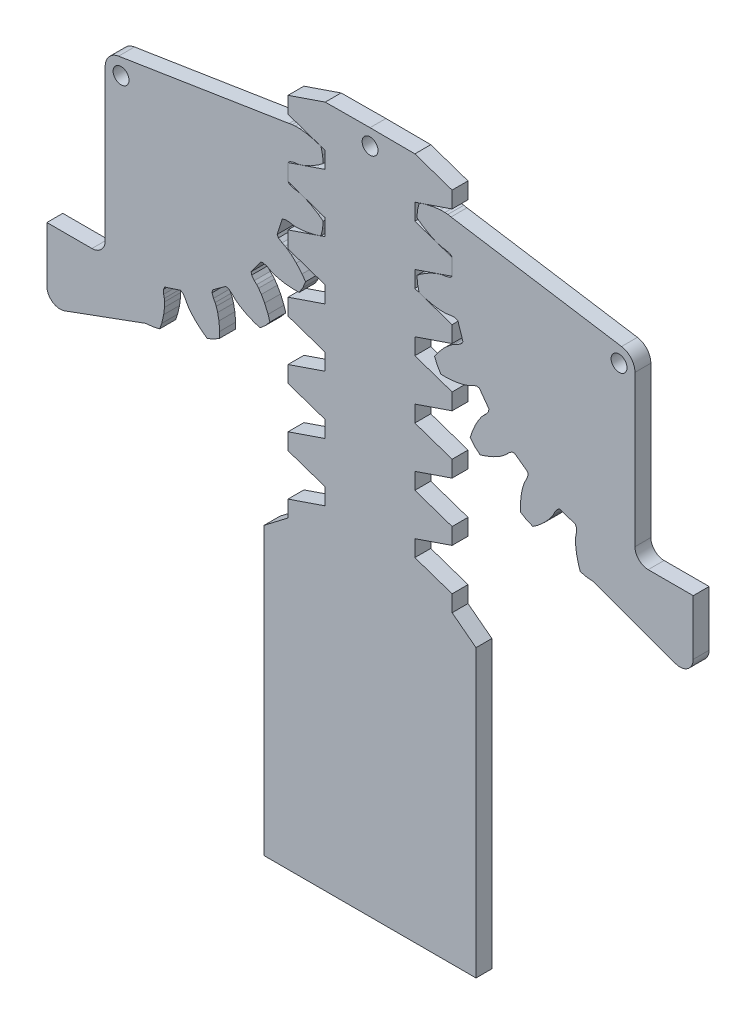
from build123d import *

# Parameters (mm, degrees)
MODEL_R            = 3
BOSS_EXTRU_1_DEPTH = 6
MODEL_4_R          = 3
BOSS_EXTRU_2_DEPTH = 6
MODEL_5_R          = 3
BOSS_EXTRU_3_DEPTH = 6


with BuildPart() as part:
    # Model → Boss.-Extru.1 (new body)
    with BuildSketch(Plane.XY):
        Polygon((-40, 168), (-40, 60), (0, 60), (40, 60), (40, 168), (30.974642536, 174.908406866), (30.974642536, 181.091593134), (16.919007544, 185.898903429), (16.919007544, 192.101096571), (30.974642536, 196.908406866), (30.974642536, 203.091593134), (16.919007544, 207.898903429), (16.919007544, 214.101096571), (30.974642536, 218.908406866), (30.974642536, 225.091593134), (16.919007544, 229.898903429), (16.919007544, 236.101096571), (30.974642536, 240.908406866), (30.974642536, 247.091593134), (16.919007544, 251.898903429), (16.919007544, 258.101096571), (30.974642536, 262.908406866), (30.974642536, 269.091593134), (16.919007544, 273.898903429), (16.919007544, 280.101096571), (30.974642536, 284.908406866), (30.974642536, 291.091593134), (16.919007544, 295.898903429), (16.919007544, 302.101096571), (30.974642536, 306.908406866), (30.974642536, 313.091593134), (16.919007544, 317.898903429), (0, 318), (-16.919007544, 317.898903429), (-30.974642536, 313.091593134), (-30.974642536, 306.908406866), (-16.919007544, 302.101096571), (-16.919007544, 295.898903429), (-30.974642536, 291.091593134), (-30.974642536, 284.908406866), (-16.919007544, 280.101096571), (-16.919007544, 273.898903429), (-30.974642536, 269.091593134), (-30.974642536, 262.908406866), (-16.919007544, 258.101096571), (-16.919007544, 251.898903429), (-30.974642536, 247.091593134), (-30.974642536, 240.908406866), (-16.919007544, 236.101096571), (-16.919007544, 229.898903429), (-30.974642536, 225.091593134), (-30.974642536, 218.908406866), (-16.919007544, 214.101096571), (-16.919007544, 207.898903429), (-30.974642536, 203.091593134), (-30.974642536, 196.908406866), (-16.919007544, 192.101096571), (-16.919007544, 185.898903429), (-30.974642536, 181.091593134), (-30.974642536, 174.908406866), align=None)
        with Locations((0, 312)):
            Circle(MODEL_R, mode=Mode.SUBTRACT)
    extrude(amount=BOSS_EXTRU_1_DEPTH)


with BuildPart() as body_2:
    # Model_4 → Boss.-Extru.2 (new body)
    with BuildSketch(Plane.XY):
        with BuildLine():
            Line((-24.68488417, 293.282723858), (-26.413806818, 292.691397487))
            Line((-26.413806818, 292.691397487), (-27.486087265, 292.446172482))
            Line((-27.486087265, 292.446172482), (-28.703913807, 292.299193468))
            Line((-28.703913807, 292.299193468), (-30.277542749, 291.807781018))
            Line((-30.277542749, 291.807781018), (-31.024642536, 291.114398793))
            Line((-31.024642536, 291.114398793), (-31.024642536, 284.885601207))
            Line((-31.024642536, 284.885601207), (-30.277542749, 284.192218982))
            Line((-30.277542749, 284.192218982), (-28.703913807, 283.700806532))
            Line((-28.703913807, 283.700806532), (-27.486087265, 283.553827518))
            Line((-27.486087265, 283.553827518), (-26.413806818, 283.308602513))
            Line((-26.413806818, 283.308602513), (-24.68488417, 282.717276142))
            Line((-24.68488417, 282.717276142), (-22.367465587, 281.642464729))
            Line((-22.367465587, 281.642464729), (-19.55091319, 279.95801306))
            Line((-19.55091319, 279.95801306), (-17.710599237, 278.577184116))
            Line((-17.710599237, 278.577184116), (-17.917386886, 275.949697904))
            Line((-17.917386886, 275.949697904), (-18.532658037, 273.386909122))
            Line((-18.532658037, 273.386909122), (-20.709600224, 272.642351043))
            Line((-20.709600224, 272.642351043), (-23.908824927, 271.910704863))
            Line((-23.908824927, 271.910704863), (-26.444955963, 271.604620191))
            Line((-26.444955963, 271.604620191), (-28.271989012, 271.576501872))
            Line((-28.271989012, 271.576501872), (-29.367567013, 271.674631914))
            Line((-29.367567013, 271.674631914), (-30.571207893, 271.911175663))
            Line((-30.571207893, 271.911175663), (-32.219672752, 271.930092736))
            Line((-32.219672752, 271.930092736), (-33.144473763, 271.501513584))
            Line((-33.144473763, 271.501513584), (-35.069278072, 265.57757505))
            Line((-35.069278072, 265.57757505), (-34.573010843, 264.687262837))
            Line((-34.573010843, 264.687262837), (-33.228255581, 263.733623737))
            Line((-33.228255581, 263.733623737), (-32.115452726, 263.217509291))
            Line((-32.115452726, 263.217509291), (-31.171432113, 262.652933571))
            Line((-31.171432113, 262.652933571), (-29.709858861, 261.556282292))
            Line((-29.709858861, 261.556282292), (-27.837997809, 259.817954169))
            Line((-27.837997809, 259.817954169), (-25.67982149, 257.345582877))
            Line((-25.67982149, 257.345582877), (-24.356278523, 255.463648225))
            Line((-24.356278523, 255.463648225), (-25.364883157, 253.028661239))
            Line((-25.364883157, 253.028661239), (-26.74198608, 250.781433511))
            Line((-26.74198608, 250.781433511), (-29.042462232, 250.746028829))
            Line((-29.042462232, 250.746028829), (-32.311196837, 251.038806764))
            Line((-32.311196837, 251.038806764), (-34.81778615, 251.531410532))
            Line((-34.81778615, 251.531410532), (-36.564086875, 252.069252683))
            Line((-36.564086875, 252.069252683), (-37.575719621, 252.50113212))
            Line((-37.575719621, 252.50113212), (-38.647354086, 253.098044081))
            Line((-38.647354086, 253.098044081), (-40.209291635, 253.625438942))
            Line((-40.209291635, 253.625438942), (-41.221267904, 253.503615176))
            Line((-41.221267904, 253.503615176), (-44.882463265, 248.464412073))
            Line((-44.882463265, 248.464412073), (-44.685606687, 247.464319834))
            Line((-44.685606687, 247.464319834), (-43.701359121, 246.141802925))
            Line((-43.701359121, 246.141802925), (-42.802508849, 245.307073925))
            Line((-42.802508849, 245.307073925), (-42.079155386, 244.478412095))
            Line((-42.079155386, 244.478412095), (-41.028000502, 242.983783776))
            Line((-41.028000502, 242.983783776), (-39.784927783, 240.752098611))
            Line((-39.784927783, 240.752098611), (-38.496384877, 237.733820623))
            Line((-38.496384877, 237.733820623), (-37.819170504, 235.53499714))
            Line((-37.819170504, 235.53499714), (-39.530862872, 233.530862872))
            Line((-39.530862872, 233.530862872), (-41.53499714, 231.819170504))
            Line((-41.53499714, 231.819170504), (-43.733820623, 232.496384877))
            Line((-43.733820623, 232.496384877), (-46.752098611, 233.784927783))
            Line((-46.752098611, 233.784927783), (-48.983783776, 235.028000502))
            Line((-48.983783776, 235.028000502), (-50.478412095, 236.079155386))
            Line((-50.478412095, 236.079155386), (-51.307073925, 236.802508849))
            Line((-51.307073925, 236.802508849), (-52.141802925, 237.701359121))
            Line((-52.141802925, 237.701359121), (-53.464319834, 238.685606687))
            Line((-53.464319834, 238.685606687), (-54.464412073, 238.882463265))
            Line((-54.464412073, 238.882463265), (-59.503615176, 235.221267904))
            Line((-59.503615176, 235.221267904), (-59.625438942, 234.209291635))
            Line((-59.625438942, 234.209291635), (-59.098044081, 232.647354086))
            Line((-59.098044081, 232.647354086), (-58.50113212, 231.575719621))
            Line((-58.50113212, 231.575719621), (-58.069252683, 230.564086875))
            Line((-58.069252683, 230.564086875), (-57.531410532, 228.81778615))
            Line((-57.531410532, 228.81778615), (-57.038806764, 226.311196837))
            Line((-57.038806764, 226.311196837), (-56.746028829, 223.042462232))
            Line((-56.746028829, 223.042462232), (-56.78143351, 220.74198608))
            Line((-56.78143351, 220.74198608), (-59.028661239, 219.364883157))
            Line((-59.028661239, 219.364883157), (-61.463648225, 218.356278523))
            Line((-61.463648225, 218.356278523), (-63.345582877, 219.67982149))
            Line((-63.345582877, 219.67982149), (-65.817954169, 221.837997809))
            Line((-65.817954169, 221.837997809), (-67.556282292, 223.709858861))
            Line((-67.556282292, 223.709858861), (-68.652933571, 225.171432113))
            Line((-68.652933571, 225.171432113), (-69.217509291, 226.115452726))
            Line((-69.217509291, 226.115452726), (-69.733623737, 227.228255581))
            Line((-69.733623737, 227.228255581), (-70.687262837, 228.573010843))
            Line((-70.687262837, 228.573010843), (-71.57757505, 229.069278072))
            Line((-71.57757505, 229.069278072), (-77.501513584, 227.144473763))
            Line((-77.501513584, 227.144473763), (-77.930092736, 226.219672752))
            Line((-77.930092736, 226.219672752), (-77.911175663, 224.571207893))
            Line((-77.911175663, 224.571207893), (-77.674631914, 223.367567013))
            Line((-77.674631914, 223.367567013), (-77.576501872, 222.271989012))
            Line((-77.576501872, 222.271989012), (-77.604620191, 220.444955963))
            Line((-77.604620191, 220.444955963), (-77.910704863, 217.908824927))
            Line((-77.910704863, 217.908824927), (-78.642351043, 214.709600224))
            Line((-78.642351043, 214.709600224), (-79.386909122, 212.532658037))
            Line((-79.386909122, 212.532658037), (-81.949697904, 211.917386886))
            Line((-81.949697904, 211.917386886), (-84.577184116, 211.710599237))
            Line((-84.577184116, 211.710599237), (-115.280447058, 200.465495642))
            ThreePointArc((-115.280447058, 200.465495642), (-119.863759521, 201.06186348), (-122.000000293, 205.160507535))
            Line((-122.000000293, 205.160507535), (-122.000000293, 226))
            Line((-122.000000293, 226), (-105, 226))
            ThreePointArc((-105, 226), (-101.464466094, 227.464466094), (-100, 231))
            Line((-100, 231), (-100, 288))
            ThreePointArc((-100, 288), (-98.561487699, 291.897798093), (-94.935723343, 293.926586018))
            Line((-94.935723343, 293.926586018), (-30.571207893, 304.088824337))
            Line((-30.571207893, 304.088824337), (-29.367567013, 304.325368086))
            Line((-29.367567013, 304.325368086), (-28.271989012, 304.423498128))
            Line((-28.271989012, 304.423498128), (-26.444955963, 304.395379809))
            Line((-26.444955963, 304.395379809), (-23.908824927, 304.089295137))
            Line((-23.908824927, 304.089295137), (-20.709600224, 303.357648957))
            Line((-20.709600224, 303.357648957), (-18.532658037, 302.613090878))
            Line((-18.532658037, 302.613090878), (-17.917386886, 300.050302096))
            Line((-17.917386886, 300.050302096), (-17.710599237, 297.422815884))
            Line((-17.710599237, 297.422815884), (-19.55091319, 296.04198694))
            Line((-19.55091319, 296.04198694), (-22.367465587, 294.357535271))
            Line((-22.367465587, 294.357535271), (-24.68488417, 293.282723858))
        make_face()
        with Locations((-94, 288)):
            Circle(MODEL_4_R, mode=Mode.SUBTRACT)
    extrude(amount=BOSS_EXTRU_2_DEPTH)


with BuildPart() as body_3:
    # Model_5 → Boss.-Extru.3 (new body)
    with BuildSketch(Plane.XY):
        with BuildLine():
            Line((24.684884169, 293.282723858), (26.413806818, 292.691397486))
            Line((26.413806818, 292.691397486), (27.486087265, 292.446172482))
            Line((27.486087265, 292.446172482), (28.703913806, 292.299193468))
            Line((28.703913806, 292.299193468), (30.277542749, 291.807781017))
            Line((30.277542749, 291.807781017), (31.024642536, 291.114398793))
            Line((31.024642536, 291.114398793), (31.024642536, 284.885601206))
            Line((31.024642536, 284.885601206), (30.277542749, 284.192218982))
            Line((30.277542749, 284.192218982), (28.703913806, 283.700806532))
            Line((28.703913806, 283.700806532), (27.486087265, 283.553827518))
            Line((27.486087265, 283.553827518), (26.413806818, 283.308602513))
            Line((26.413806818, 283.308602513), (24.684884169, 282.717276141))
            Line((24.684884169, 282.717276141), (22.367465587, 281.642464729))
            Line((22.367465587, 281.642464729), (19.55091319, 279.95801306))
            Line((19.55091319, 279.95801306), (17.710599237, 278.577184115))
            Line((17.710599237, 278.577184115), (17.917386886, 275.949697903))
            Line((17.917386886, 275.949697903), (18.532658037, 273.386909122))
            Line((18.532658037, 273.386909122), (20.709600224, 272.642351043))
            Line((20.709600224, 272.642351043), (23.908824927, 271.910704863))
            Line((23.908824927, 271.910704863), (26.444955963, 271.604620191))
            Line((26.444955963, 271.604620191), (28.271989012, 271.576501872))
            Line((28.271989012, 271.576501872), (29.367567013, 271.674631914))
            Line((29.367567013, 271.674631914), (30.571207893, 271.911175663))
            Line((30.571207893, 271.911175663), (32.219672752, 271.930092735))
            Line((32.219672752, 271.930092735), (33.144473763, 271.501513583))
            Line((33.144473763, 271.501513583), (35.069278072, 265.57757505))
            Line((35.069278072, 265.57757505), (34.573010842, 264.687262837))
            Line((34.573010842, 264.687262837), (33.228255581, 263.733623737))
            Line((33.228255581, 263.733623737), (32.115452726, 263.217509291))
            Line((32.115452726, 263.217509291), (31.171432113, 262.652933571))
            Line((31.171432113, 262.652933571), (29.70985886, 261.556282292))
            Line((29.70985886, 261.556282292), (27.837997809, 259.817954169))
            Line((27.837997809, 259.817954169), (25.67982149, 257.345582877))
            Line((25.67982149, 257.345582877), (24.356278523, 255.463648225))
            Line((24.356278523, 255.463648225), (25.364883157, 253.028661239))
            Line((25.364883157, 253.028661239), (26.74198608, 250.78143351))
            Line((26.74198608, 250.78143351), (29.042462232, 250.746028829))
            Line((29.042462232, 250.746028829), (32.311196837, 251.038806764))
            Line((32.311196837, 251.038806764), (34.81778615, 251.531410532))
            Line((34.81778615, 251.531410532), (36.564086875, 252.069252683))
            Line((36.564086875, 252.069252683), (37.575719621, 252.50113212))
            Line((37.575719621, 252.50113212), (38.647354086, 253.098044081))
            Line((38.647354086, 253.098044081), (40.209291635, 253.625438942))
            Line((40.209291635, 253.625438942), (41.221267904, 253.503615176))
            Line((41.221267904, 253.503615176), (44.882463265, 248.464412073))
            Line((44.882463265, 248.464412073), (44.685606687, 247.464319834))
            Line((44.685606687, 247.464319834), (43.70135912, 246.141802925))
            Line((43.70135912, 246.141802925), (42.802508849, 245.307073925))
            Line((42.802508849, 245.307073925), (42.079155386, 244.478412095))
            Line((42.079155386, 244.478412095), (41.028000502, 242.983783776))
            Line((41.028000502, 242.983783776), (39.784927783, 240.752098611))
            Line((39.784927783, 240.752098611), (38.496384877, 237.733820623))
            Line((38.496384877, 237.733820623), (37.819170504, 235.53499714))
            Line((37.819170504, 235.53499714), (39.530862872, 233.530862872))
            Line((39.530862872, 233.530862872), (41.53499714, 231.819170504))
            Line((41.53499714, 231.819170504), (43.733820623, 232.496384877))
            Line((43.733820623, 232.496384877), (46.752098611, 233.784927783))
            Line((46.752098611, 233.784927783), (48.983783776, 235.028000502))
            Line((48.983783776, 235.028000502), (50.478412095, 236.079155386))
            Line((50.478412095, 236.079155386), (51.307073925, 236.802508849))
            Line((51.307073925, 236.802508849), (52.141802925, 237.701359121))
            Line((52.141802925, 237.701359121), (53.464319834, 238.685606687))
            Line((53.464319834, 238.685606687), (54.464412073, 238.882463265))
            Line((54.464412073, 238.882463265), (59.503615176, 235.221267904))
            Line((59.503615176, 235.221267904), (59.625438942, 234.209291635))
            Line((59.625438942, 234.209291635), (59.098044081, 232.647354086))
            Line((59.098044081, 232.647354086), (58.50113212, 231.575719621))
            Line((58.50113212, 231.575719621), (58.069252683, 230.564086875))
            Line((58.069252683, 230.564086875), (57.531410532, 228.81778615))
            Line((57.531410532, 228.81778615), (57.038806764, 226.311196837))
            Line((57.038806764, 226.311196837), (56.746028829, 223.042462232))
            Line((56.746028829, 223.042462232), (56.78143351, 220.74198608))
            Line((56.78143351, 220.74198608), (59.028661239, 219.364883157))
            Line((59.028661239, 219.364883157), (61.463648225, 218.356278523))
            Line((61.463648225, 218.356278523), (63.345582877, 219.67982149))
            Line((63.345582877, 219.67982149), (65.817954169, 221.837997809))
            Line((65.817954169, 221.837997809), (67.556282292, 223.70985886))
            Line((67.556282292, 223.70985886), (68.652933571, 225.171432113))
            Line((68.652933571, 225.171432113), (69.217509291, 226.115452726))
            Line((69.217509291, 226.115452726), (69.733623737, 227.228255581))
            Line((69.733623737, 227.228255581), (70.687262837, 228.573010843))
            Line((70.687262837, 228.573010843), (71.57757505, 229.069278072))
            Line((71.57757505, 229.069278072), (77.501513583, 227.144473763))
            Line((77.501513583, 227.144473763), (77.930092735, 226.219672752))
            Line((77.930092735, 226.219672752), (77.911175663, 224.571207893))
            Line((77.911175663, 224.571207893), (77.674631914, 223.367567013))
            Line((77.674631914, 223.367567013), (77.576501872, 222.271989012))
            Line((77.576501872, 222.271989012), (77.604620191, 220.444955963))
            Line((77.604620191, 220.444955963), (77.910704863, 217.908824927))
            Line((77.910704863, 217.908824927), (78.642351043, 214.709600224))
            Line((78.642351043, 214.709600224), (79.386909122, 212.532658037))
            Line((79.386909122, 212.532658037), (81.949697903, 211.917386886))
            Line((81.949697903, 211.917386886), (84.577184115, 211.710599237))
            Line((84.577184115, 211.710599237), (115.280447058, 200.465495642))
            ThreePointArc((115.280447058, 200.465495642), (119.86375952, 201.06186348), (122.000000293, 205.160507535))
            Line((122.000000293, 205.160507535), (122.000000293, 226))
            Line((122.000000293, 226), (105, 226))
            ThreePointArc((105, 226), (101.464466094, 227.464466094), (100, 231))
            Line((100, 231), (100, 288))
            ThreePointArc((100, 288), (98.561487699, 291.897798093), (94.935723342, 293.926586018))
            Line((94.935723342, 293.926586018), (30.571207893, 304.088824337))
            Line((30.571207893, 304.088824337), (29.367567013, 304.325368086))
            Line((29.367567013, 304.325368086), (28.271989012, 304.423498128))
            Line((28.271989012, 304.423498128), (26.444955963, 304.395379809))
            Line((26.444955963, 304.395379809), (23.908824927, 304.089295137))
            Line((23.908824927, 304.089295137), (20.709600224, 303.357648957))
            Line((20.709600224, 303.357648957), (18.532658037, 302.613090878))
            Line((18.532658037, 302.613090878), (17.917386886, 300.050302096))
            Line((17.917386886, 300.050302096), (17.710599237, 297.422815884))
            Line((17.710599237, 297.422815884), (19.55091319, 296.04198694))
            Line((19.55091319, 296.04198694), (22.367465587, 294.357535271))
            Line((22.367465587, 294.357535271), (24.684884169, 293.282723858))
        make_face()
        with Locations((94, 288)):
            Circle(MODEL_5_R, mode=Mode.SUBTRACT)
    extrude(amount=BOSS_EXTRU_3_DEPTH)


solid = Compound([part.part, body_2.part, body_3.part])
